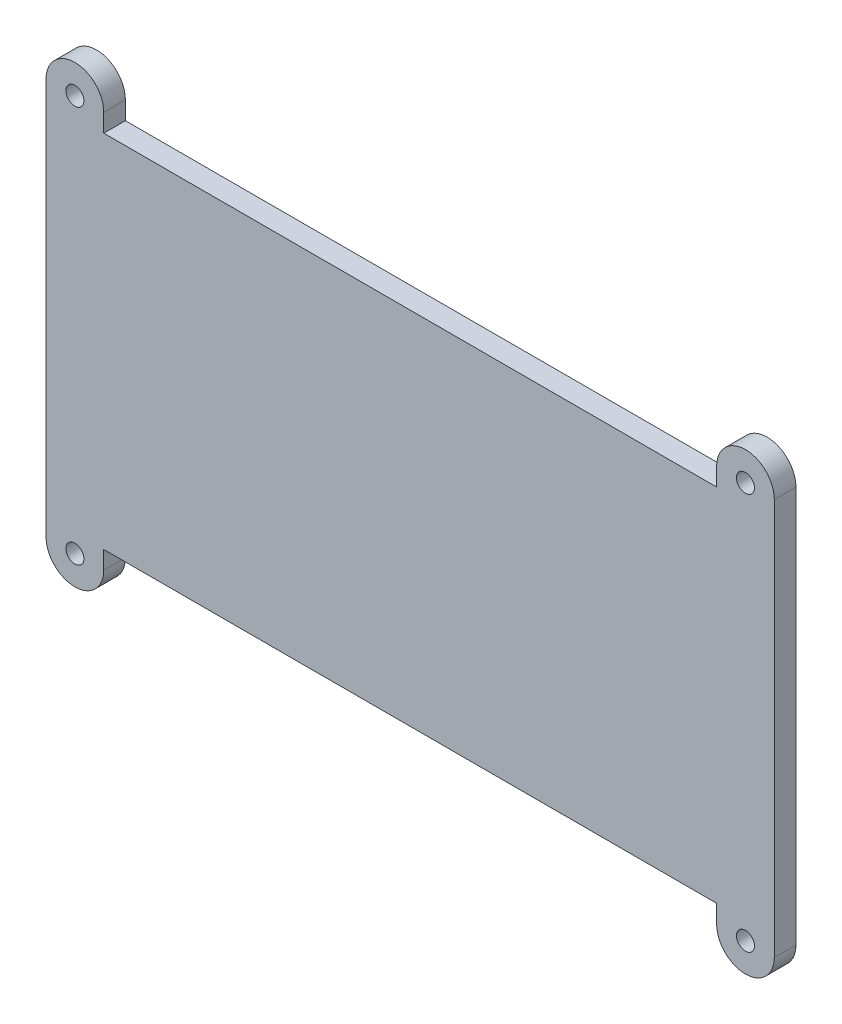
from build123d import *

# Parameters (mm, degrees)
SKETCH1_R           = 1.25
BOSS_EXTRUDE1_DEPTH = 3


with BuildPart() as part:
    # Sketch1 → Boss-Extrude1 (new body)
    with BuildSketch(Plane.XY):
        with BuildLine():
            Line((-42.5, -27.5), (-42.5, -25))
            Line((-42.5, -25), (42.5, -25))
            Line((42.5, -25), (42.5, -27.5))
            ThreePointArc((42.5, -27.5), (46.5, -31.5), (50.5, -27.5))
            Line((50.5, -27.5), (50.5, -25))
            Line((50.5, -25), (50.5, 25))
            Line((50.5, 25), (50.5, 27.5))
            ThreePointArc((50.5, 27.5), (46.5, 31.5), (42.5, 27.5))
            Line((42.5, 27.5), (42.5, 25))
            Line((42.5, 25), (-42.5, 25))
            Line((-42.5, 25), (-42.5, 27.5))
            ThreePointArc((-42.5, 27.5), (-46.5, 31.5), (-50.5, 27.5))
            Line((-50.5, 27.5), (-50.5, 25))
            Line((-50.5, 25), (-50.5, -25))
            Line((-50.5, -25), (-50.5, -27.5))
            ThreePointArc((-50.5, -27.5), (-46.5, -31.5), (-42.5, -27.5))
        make_face()
        with Locations((-46.5, 27.5)):
            Circle(SKETCH1_R, mode=Mode.SUBTRACT)
        with Locations((46.5, 27.5)):
            Circle(SKETCH1_R, mode=Mode.SUBTRACT)
        with Locations((46.5, -27.5)):
            Circle(SKETCH1_R, mode=Mode.SUBTRACT)
        with Locations((-46.5, -27.5)):
            Circle(SKETCH1_R, mode=Mode.SUBTRACT)
    extrude(amount=BOSS_EXTRUDE1_DEPTH)


solid = part.part
